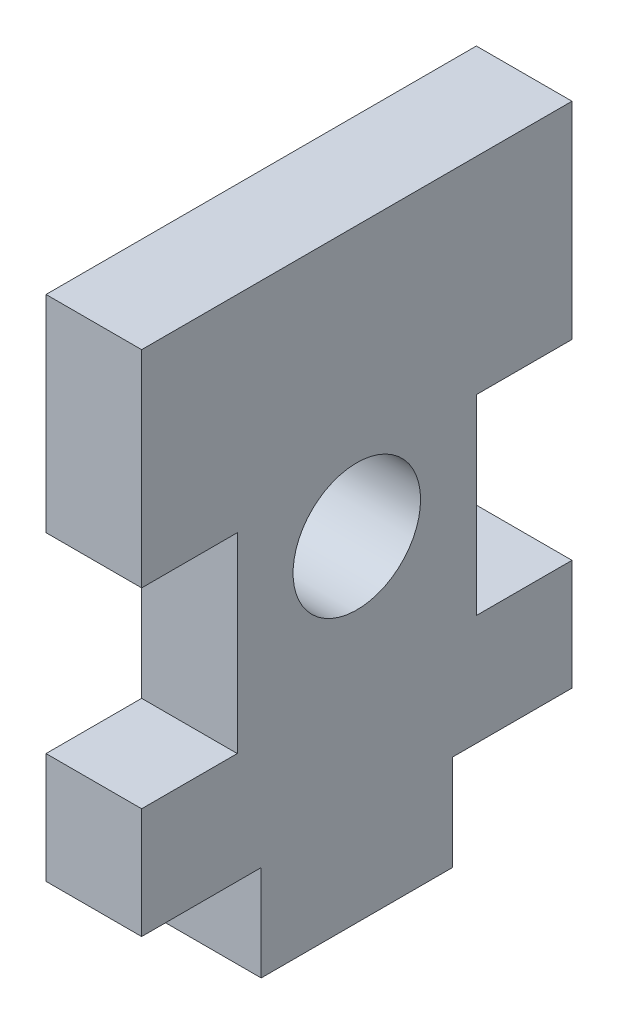
from build123d import *

# Parameters (mm, degrees)
SKETCH1_R           = 4
BOSS_EXTRUDE1_DEPTH = 6


with BuildPart() as part:
    # Sketch1 → Boss-Extrude1 (new body)
    with BuildSketch(Plane(origin=(0, 0, 0), x_dir=(0, 0, -1), z_dir=(1, 0, 0))):
        Polygon((-7.5, 0), (-6, 0), (-6, -6), (6, -6), (6, 0), (7.5, 0), (13.5, 0), (13.5, 6.945859109), (7.5, 6.945859109), (7.5, 18.945859109), (13.5, 18.945859109), (13.5, 31.891718217), (-13.5, 31.891718217), (-13.5, 18.945859109), (-7.5, 18.945859109), (-7.5, 6.945859109), (-13.5, 6.945859109), (-13.5, 0), align=None)
        with Locations((0, 15)):
            Circle(SKETCH1_R, mode=Mode.SUBTRACT)
    extrude(amount=BOSS_EXTRUDE1_DEPTH)


solid = part.part
